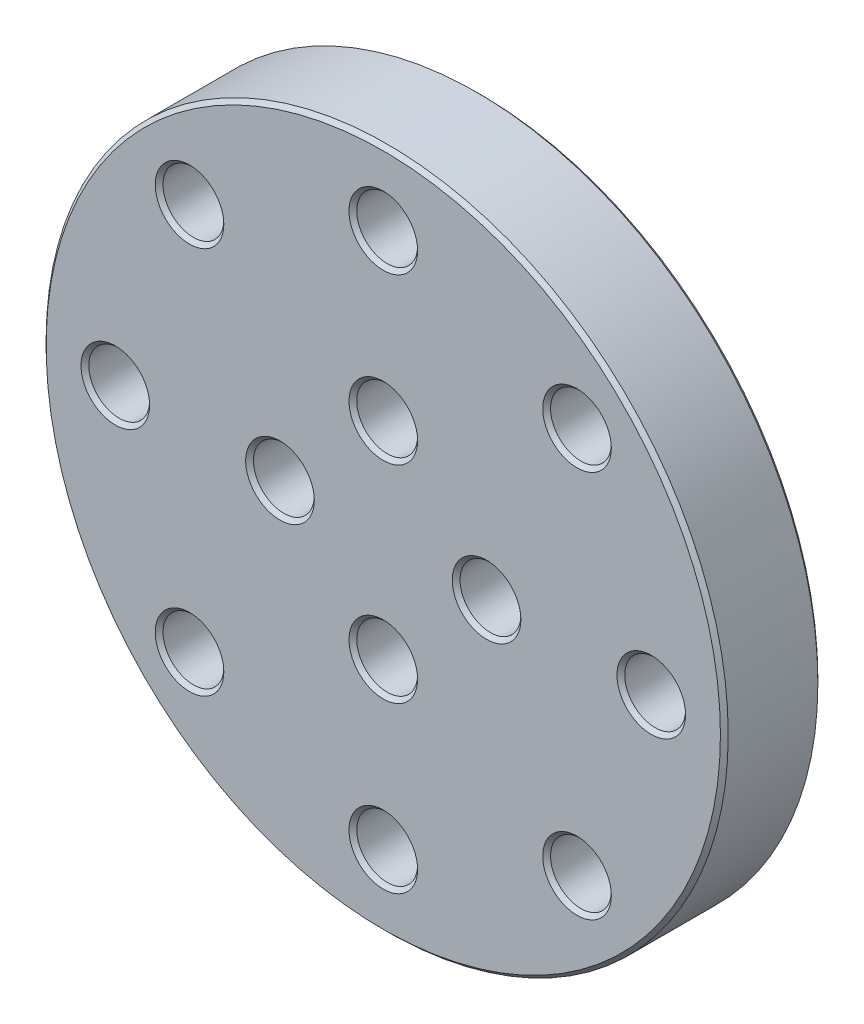
from build123d import *

# Parameters (mm, degrees)
SKETCH1_R          = 44.45
EXTRUDE1_DEPTH     = 12.7
SKETCH2_R          = 3.9624
CUT_EXTRUDE3_DEPTH = 13.7
SKETCH3_R          = 3.9624
CUT_EXTRUDE4_DEPTH = 13.7
CIRPATTERN1_COUNT  = 4
CHAMFER1_SIZE      = 0.508
SKETCH4_R          = 3.9624
CUT_EXTRUDE8_DEPTH = 13.7
CIRPATTERN3_COUNT  = 4
CHAMFER2_SIZE      = 0.508
CHAMFER3_SIZE      = 0.508


with BuildPart() as part:
    # Sketch1 → Extrude1 (new body)
    with BuildSketch(Plane.XY):
        Circle(SKETCH1_R)
    extrude(amount=EXTRUDE1_DEPTH)

    # Sketch2 → Cut-Extrude3 (cut, through all)
    with BuildSketch(Plane.XY):
        with Locations((0, 13.462)):
            Circle(SKETCH2_R)
        with Locations((13.462, 0)):
            Circle(SKETCH2_R)
        with Locations((0, -13.462)):
            Circle(SKETCH2_R)
        with Locations((-13.462, 0)):
            Circle(SKETCH2_R)
    extrude(amount=CUT_EXTRUDE3_DEPTH, mode=Mode.SUBTRACT)

    # Sketch3 → Cut-Extrude4 (cut, through all)
    with BuildSketch(Plane.XY):
        with Locations((0, -34.925)):
            Circle(SKETCH3_R)
    cut_extrude4 = extrude(amount=CUT_EXTRUDE4_DEPTH, mode=Mode.SUBTRACT)

    # CirPattern1: Cut-Extrude4 ×4 about axis
    cirpattern1_axis = Axis((0, 0, 0), (0, 0, 1))
    for i in range(1, CIRPATTERN1_COUNT):
        add(cut_extrude4.rotate(cirpattern1_axis, i * 360 / CIRPATTERN1_COUNT), mode=Mode.SUBTRACT)

    # Chamfer1
    chamfer1_edges = [part.edges().sort_by_distance(p)[0] for p in [
        (-3.9624, 13.462, 0),
        (-3.9624, 13.462, 12.7),
        (9.4996, 0, 12.7),
        (-3.9624, -13.462, 12.7),
        (-3.9624, -34.925, 0),
        (-3.9624, -34.925, 12.7),
        (34.925, -3.9624, 0),
        (34.925, -3.9624, 12.7),
        (3.9624, 34.925, 0),
        (3.9624, 34.925, 12.7),
        (-34.925, 3.9624, 0),
        (-34.925, 3.9624, 12.7),
        (-17.4244, 0, 12.7),
    ]]
    chamfer(chamfer1_edges, length=CHAMFER1_SIZE)

    # Sketch4 → Cut-Extrude8 (cut, through all)
    with BuildSketch(Plane.XY.offset(12.7)):
        with Locations((-25.252480212, -25.252480212)):
            Circle(SKETCH4_R)
    cut_extrude8 = extrude(amount=-CUT_EXTRUDE8_DEPTH, mode=Mode.SUBTRACT)

    # CirPattern3: Cut-Extrude8 ×4 about axis
    cirpattern3_axis = Axis((0, 0, 0), (0, 0, 1))
    for i in range(1, CIRPATTERN3_COUNT):
        add(cut_extrude8.rotate(cirpattern3_axis, i * 360 / CIRPATTERN3_COUNT), mode=Mode.SUBTRACT)

    # Chamfer2
    chamfer2_edges = [part.edges().sort_by_distance(p)[0] for p in [
        (9.4996, 0, 0),
        (-3.9624, -13.462, 0),
        (-17.4244, 0, 0),
        (-29.214880212, -25.252480212, 0),
        (-29.214880212, -25.252480212, 12.7),
        (25.252480212, -29.214880212, 0),
        (25.252480212, -29.214880212, 12.7),
        (29.214880212, 25.252480212, 0),
        (29.214880212, 25.252480212, 12.7),
        (-25.252480212, 29.214880212, 0),
        (-25.252480212, 29.214880212, 12.7),
    ]]
    chamfer(chamfer2_edges, length=CHAMFER2_SIZE)

    # Chamfer3
    chamfer3_edges = [part.edges().sort_by_distance(p)[0] for p in [
        (-44.45, 0, 0),
        (-44.45, 0, 12.7),
    ]]
    chamfer(chamfer3_edges, length=CHAMFER3_SIZE)


solid = part.part
